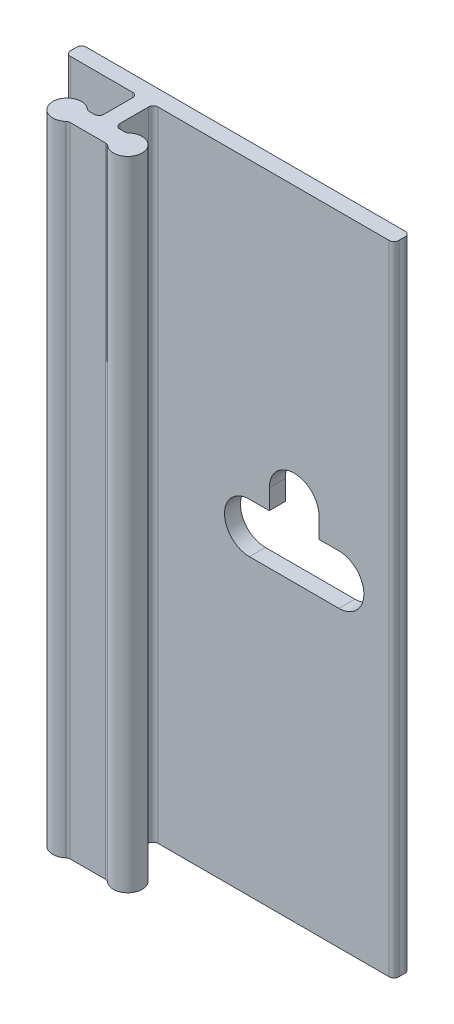
from build123d import *

# Parameters (mm, degrees)
BOSS_EXTRUDE1_DEPTH = 50.8
CUT_EXTRUDE1_DEPTH  = 2.27


with BuildPart() as part:
    # Sketch2 → Boss-Extrude1 (new body)
    with BuildSketch(Plane(origin=(0, 0, 0), x_dir=(1, 0, 0), z_dir=(0, 1, 0))):
        with BuildLine():
            Line((-5.969, 0), (19.431, 0))
            ThreePointArc((19.431, 0), (19.700407684, -0.111592316), (19.812, -0.381))
            Line((19.812, -0.381), (19.812, -0.889))
            ThreePointArc((19.812, -0.889), (19.700407684, -1.158407684), (19.431, -1.27))
            Line((19.431, -1.27), (1.016, -1.27))
            ThreePointArc((1.016, -1.27), (0.746592316, -1.381592316), (0.635, -1.651))
            Line((0.635, -1.651), (0.635, -3.937))
            ThreePointArc((0.635, -3.937), (0.746592316, -4.206407684), (1.016, -4.318))
            Line((1.016, -4.318), (1.40496875, -4.318))
            ThreePointArc((1.40496875, -4.318), (1.539672592, -4.293392866), (1.656976563, -4.22275))
            ThreePointArc((1.656976563, -4.22275), (3.556, -5.08), (1.656976563, -5.93725))
            ThreePointArc((1.656976563, -5.93725), (1.539672592, -5.866607134), (1.40496875, -5.842))
            Line((1.40496875, -5.842), (-1.40496875, -5.842))
            ThreePointArc((-1.40496875, -5.842), (-1.539672592, -5.866607134), (-1.656976563, -5.93725))
            ThreePointArc((-1.656976563, -5.93725), (-3.556, -5.08), (-1.656976563, -4.22275))
            ThreePointArc((-1.656976563, -4.22275), (-1.539672592, -4.293392866), (-1.40496875, -4.318))
            Line((-1.40496875, -4.318), (-1.016, -4.318))
            ThreePointArc((-1.016, -4.318), (-0.746592316, -4.206407684), (-0.635, -3.937))
            Line((-0.635, -3.937), (-0.635, -1.651))
            ThreePointArc((-0.635, -1.651), (-0.746592316, -1.381592316), (-1.016, -1.27))
            Line((-1.016, -1.27), (-5.969, -1.27))
            ThreePointArc((-5.969, -1.27), (-6.238407684, -1.158407684), (-6.35, -0.889))
            Line((-6.35, -0.889), (-6.35, -0.381))
            ThreePointArc((-6.35, -0.381), (-6.238407684, -0.111592316), (-5.969, 0))
        make_face()
    extrude(amount=BOSS_EXTRUDE1_DEPTH)

    # Sketch3 → Cut-Extrude1 (cut, through all)
    with BuildSketch(Plane.XY.offset(1.27)):
        with BuildLine():
            Line((8.2931, 27.3812), (9.8806, 27.3812))
            Line((9.8806, 27.3812), (9.8806, 28.9814))
            ThreePointArc((9.8806, 28.9814), (11.8618, 30.9626), (13.843, 28.9814))
            Line((13.843, 28.9814), (13.843, 27.3812))
            Line((13.843, 27.3812), (15.4305, 27.3812))
            ThreePointArc((15.4305, 27.3812), (17.4117, 25.4), (15.4305, 23.4188))
            Line((15.4305, 23.4188), (8.2931, 23.4188))
            ThreePointArc((8.2931, 23.4188), (6.3119, 25.4), (8.2931, 27.3812))
        make_face()
    extrude(amount=-CUT_EXTRUDE1_DEPTH, mode=Mode.SUBTRACT)


solid = part.part
